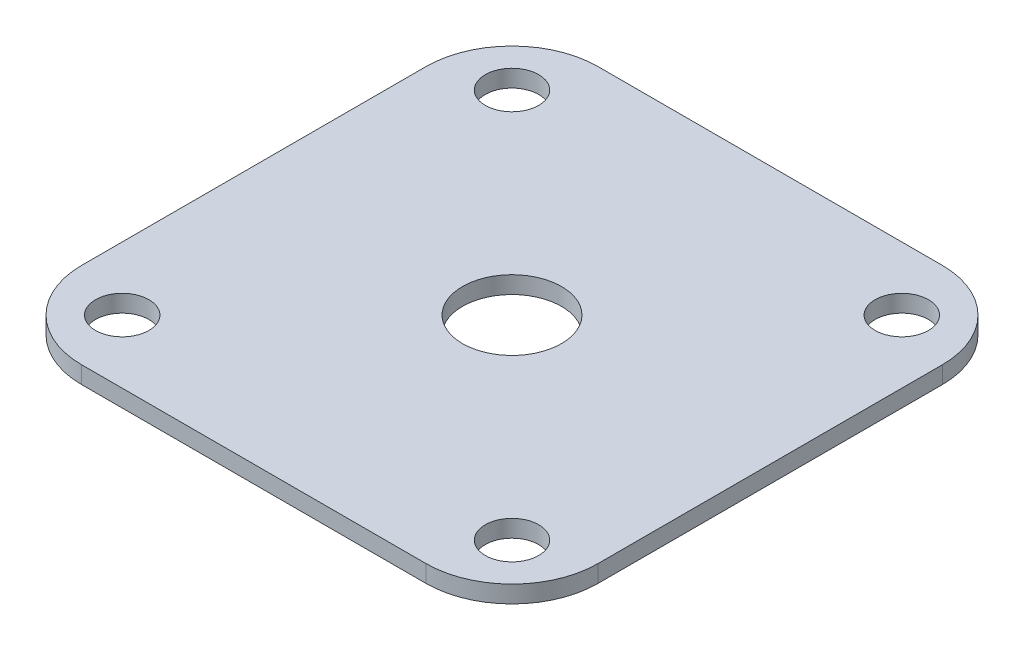
from build123d import *

# Parameters (mm, degrees)
SKETCH1_R           = 3.1
BOSS_EXTRUDE1_DEPTH = 2
SKETCH2_R           = 5.75
CUT_EXTRUDE1_DEPTH  = 3


with BuildPart() as part:
    # Sketch1 → Boss-Extrude1 (new body)
    with BuildSketch(Plane(origin=(0, 0, 0), x_dir=(1, 0, 0), z_dir=(0, 1, 0))):
        with BuildLine():
            Line((-20, -30), (20, -30))
            ThreePointArc((20, -30), (27.071067812, -27.071067812), (30, -20))
            Line((30, -20), (30, 20))
            ThreePointArc((30, 20), (27.071067812, 27.071067812), (20, 30))
            Line((20, 30), (-20, 30))
            ThreePointArc((-20, 30), (-27.071067812, 27.071067812), (-30, 20))
            Line((-30, 20), (-30, -20))
            ThreePointArc((-30, -20), (-27.071067812, -27.071067812), (-20, -30))
        make_face()
        with Locations((-22.644230769, 22.644230769)):
            Circle(SKETCH1_R, mode=Mode.SUBTRACT)
        with Locations((-22.644230769, -22.644230769)):
            Circle(SKETCH1_R, mode=Mode.SUBTRACT)
        with Locations((22.644230769, -22.644230769)):
            Circle(SKETCH1_R, mode=Mode.SUBTRACT)
        with Locations((22.644230769, 22.644230769)):
            Circle(SKETCH1_R, mode=Mode.SUBTRACT)
    extrude(amount=BOSS_EXTRUDE1_DEPTH)

    # Sketch2 → Cut-Extrude1 (cut, through all)
    with BuildSketch(Plane(origin=(0, 2, 0), x_dir=(1, 0, 0), z_dir=(0, 1, 0))):
        Circle(SKETCH2_R)
    extrude(amount=-CUT_EXTRUDE1_DEPTH, mode=Mode.SUBTRACT)


solid = part.part
